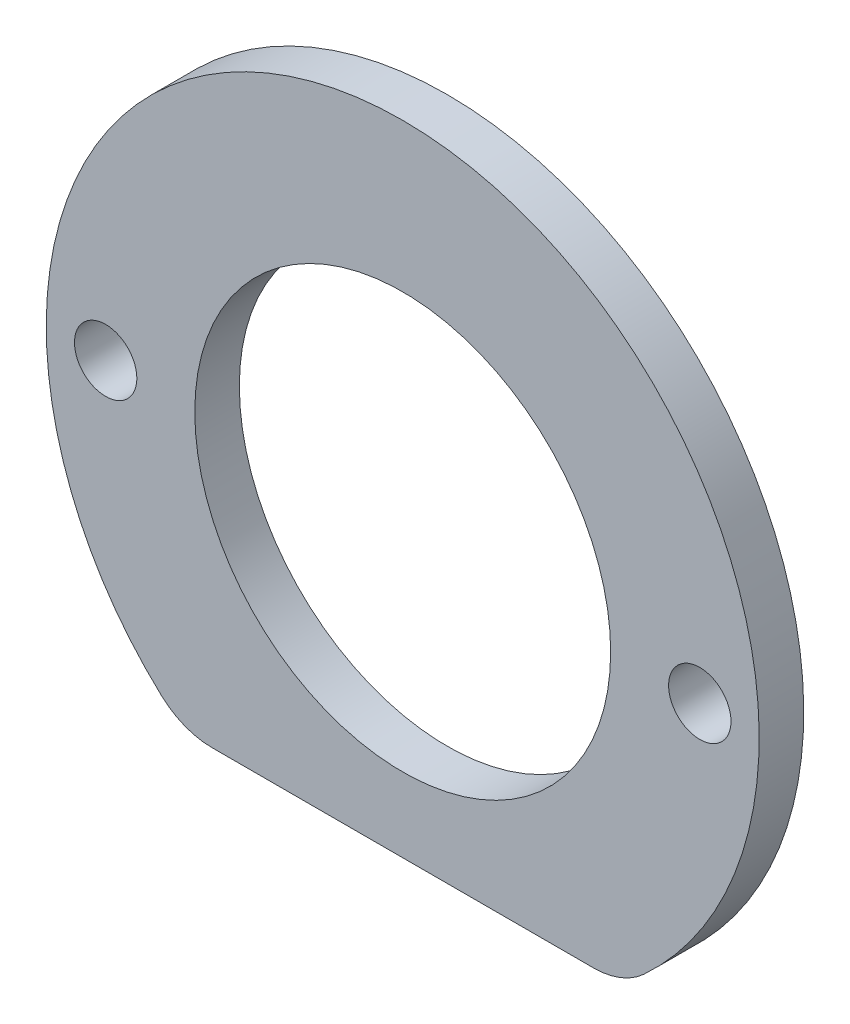
from build123d import *

# Parameters (mm, degrees)
ESBO_O1_R                = 2.1
ESBO_O1_R_2              = 14
RESSALTO_EXTRUS_O1_DEPTH = 3
FILETE1_R                = 5


with BuildPart() as part:
    # Esboço1 → Ressalto-extrusão1 (new body)
    with BuildSketch(Plane.XY):
        with BuildLine():
            Line((-14.662878299, -19), (14.662878299, -19))
            ThreePointArc((14.662878299, -19), (21.539603979, -10.585152829), (24, 0))
            ThreePointArc((24, 0), (-10.585152829, 21.539603979), (-14.662878299, -19))
        make_face()
        with Locations((-20, 0)):
            Circle(ESBO_O1_R, mode=Mode.SUBTRACT)
        Circle(ESBO_O1_R_2, mode=Mode.SUBTRACT)
        with Locations((20, 0)):
            Circle(ESBO_O1_R, mode=Mode.SUBTRACT)
    extrude(amount=RESSALTO_EXTRUS_O1_DEPTH)

    # Filete1
    filete1_edges = [part.edges().sort_by_distance(p)[0] for p in [
        (-14.662878299, -19, 1.5),
        (14.662878299, -19, 1.5),
    ]]
    fillet(filete1_edges, radius=FILETE1_R)


solid = part.part
